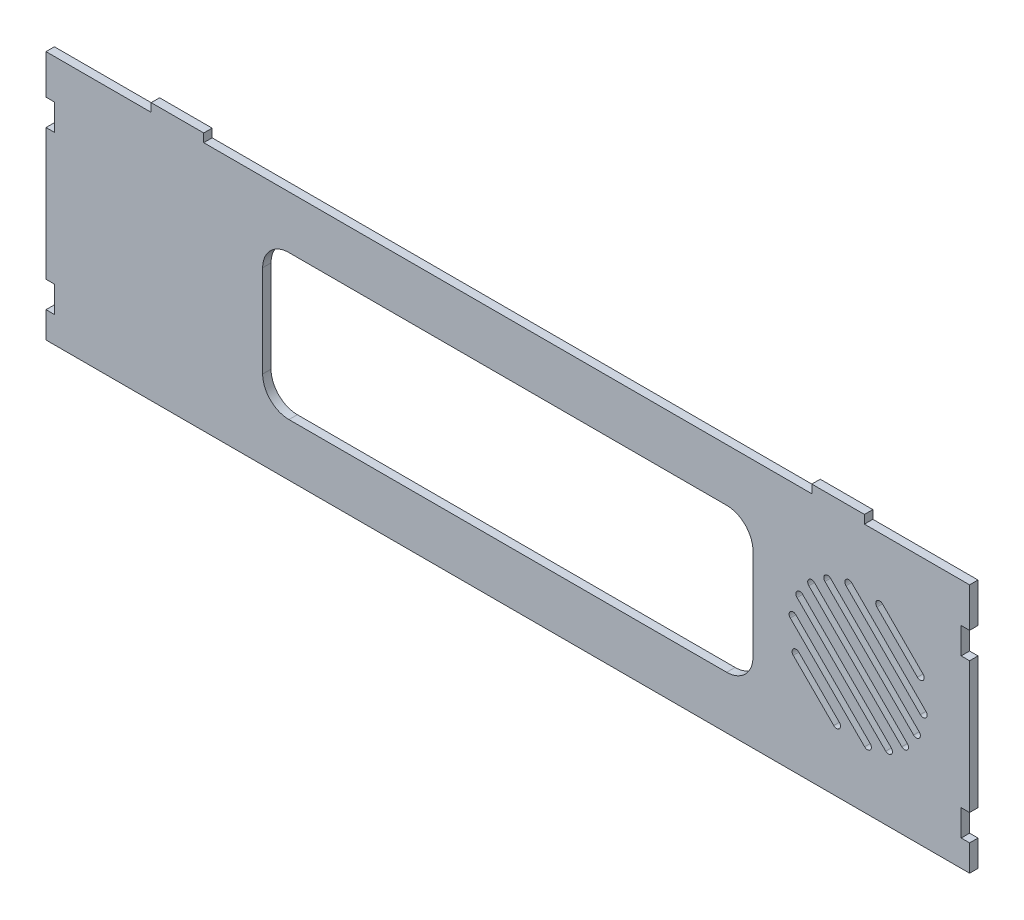
from build123d import *

# Parameters (mm, degrees)
BOSS_EXTRUDE1_DEPTH = 4.064
CUT_EXTRUDE1_DEPTH  = 5.08


with BuildPart() as part:
    # Sketch1 → Boss-Extrude1 (new body)
    with BuildSketch(Plane.XY):
        Polygon((-223.0755, -19.05), (-219.0115, -19.05), (-219.0115, -31.75), (-223.0755, -31.75), (-223.0755, -95.25), (-219.0115, -95.25), (-219.0115, -107.95), (-223.0755, -107.95), (-223.0755, -120.65), (223.0755, -120.65), (223.0755, -107.95), (219.0115, -107.95), (219.0115, -95.25), (223.0755, -95.25), (223.0755, -31.75), (219.0115, -31.75), (219.0115, -19.05), (223.0755, -19.05), (223.0755, 0), (172.2755, 0), (172.2755, 4.064), (146.8755, 4.064), (146.8755, 0), (-146.8755, 0), (-146.8755, 4.064), (-172.2755, 4.064), (-172.2755, 0), (-223.0755, 0), align=None)
    extrude(amount=BOSS_EXTRUDE1_DEPTH)

    # Sketch2 → Cut-Extrude1 (cut)
    with BuildSketch(Plane.XY.offset(4.064)):
        with BuildLine():
            Line((-105.7275, -25.4), (105.7275, -25.4))
            ThreePointArc((105.7275, -25.4), (114.707756121, -29.119743879), (118.4275, -38.1))
            Line((118.4275, -38.1), (118.4275, -82.55))
            ThreePointArc((118.4275, -82.55), (114.707756121, -91.530256121), (105.7275, -95.25))
            Line((105.7275, -95.25), (-105.7275, -95.25))
            ThreePointArc((-105.7275, -95.25), (-114.707756121, -91.530256121), (-118.4275, -82.55))
            Line((-118.4275, -82.55), (-118.4275, -38.1))
            ThreePointArc((-118.4275, -38.1), (-114.707756121, -29.119743879), (-105.7275, -25.4))
        make_face()
        with BuildLine():
            Line((137.88887808, -72.091607461), (157.460892539, -91.66362192))
            ThreePointArc((157.460892539, -91.66362192), (160.154969375, -91.66362192), (160.154969375, -88.969545084))
            Line((160.154969375, -88.969545084), (140.582954916, -69.397530625))
            ThreePointArc((140.582954916, -69.397530625), (137.88887808, -69.397530625), (137.88887808, -72.091607461))
        make_face()
        with BuildLine():
            Line((175.064666479, -90.408858006), (139.143641994, -54.487833521))
            ThreePointArc((139.143641994, -54.487833521), (136.449565158, -54.487833521), (136.449565158, -57.181910358))
            Line((136.449565158, -57.181910358), (172.370589642, -93.102934842))
            ThreePointArc((172.370589642, -93.102934842), (175.064666479, -93.102934842), (175.064666479, -90.408858006))
        make_face()
        with BuildLine():
            Line((139.728723609, -46.990684627), (182.561815373, -89.823776391))
            ThreePointArc((182.561815373, -89.823776391), (185.255892209, -89.823776391), (185.255892209, -87.129699554))
            Line((185.255892209, -87.129699554), (142.422800446, -44.296607791))
            ThreePointArc((142.422800446, -44.296607791), (139.728723609, -44.296607791), (139.728723609, -46.990684627))
        make_face()
        with BuildLine():
            Line((145.429821279, -39.221398115), (190.331101885, -84.122678721))
            ThreePointArc((190.331101885, -84.122678721), (193.025178721, -84.122678721), (193.025178721, -81.428601885))
            Line((193.025178721, -81.428601885), (148.123898115, -36.527321279))
            ThreePointArc((148.123898115, -36.527321279), (145.429821279, -36.527321279), (145.429821279, -39.221398115))
        make_face()
        with BuildLine():
            Line((153.199107791, -33.520300446), (196.032199554, -76.353392209))
            ThreePointArc((196.032199554, -76.353392209), (198.726276391, -76.353392209), (198.726276391, -73.659315373))
            Line((198.726276391, -73.659315373), (155.893184627, -30.826223609))
            ThreePointArc((155.893184627, -30.826223609), (153.199107791, -30.826223609), (153.199107791, -33.520300446))
        make_face()
        with BuildLine():
            Line((202.005434842, -63.468089642), (166.084410358, -27.547065158))
            ThreePointArc((166.084410358, -27.547065158), (163.390333521, -27.547065158), (163.390333521, -30.241141994))
            Line((163.390333521, -30.241141994), (199.311358006, -66.162166479))
            ThreePointArc((199.311358006, -66.162166479), (202.005434842, -66.162166479), (202.005434842, -63.468089642))
        make_face()
        with BuildLine():
            Line((178.300030625, -31.680454916), (197.872045084, -51.252469375))
            ThreePointArc((197.872045084, -51.252469375), (200.56612192, -51.252469375), (200.56612192, -48.558392539))
            Line((200.56612192, -48.558392539), (180.994107461, -28.98637808))
            ThreePointArc((180.994107461, -28.98637808), (178.300030625, -28.98637808), (178.300030625, -31.680454916))
        make_face()
    extrude(amount=-CUT_EXTRUDE1_DEPTH, mode=Mode.SUBTRACT)


solid = part.part
